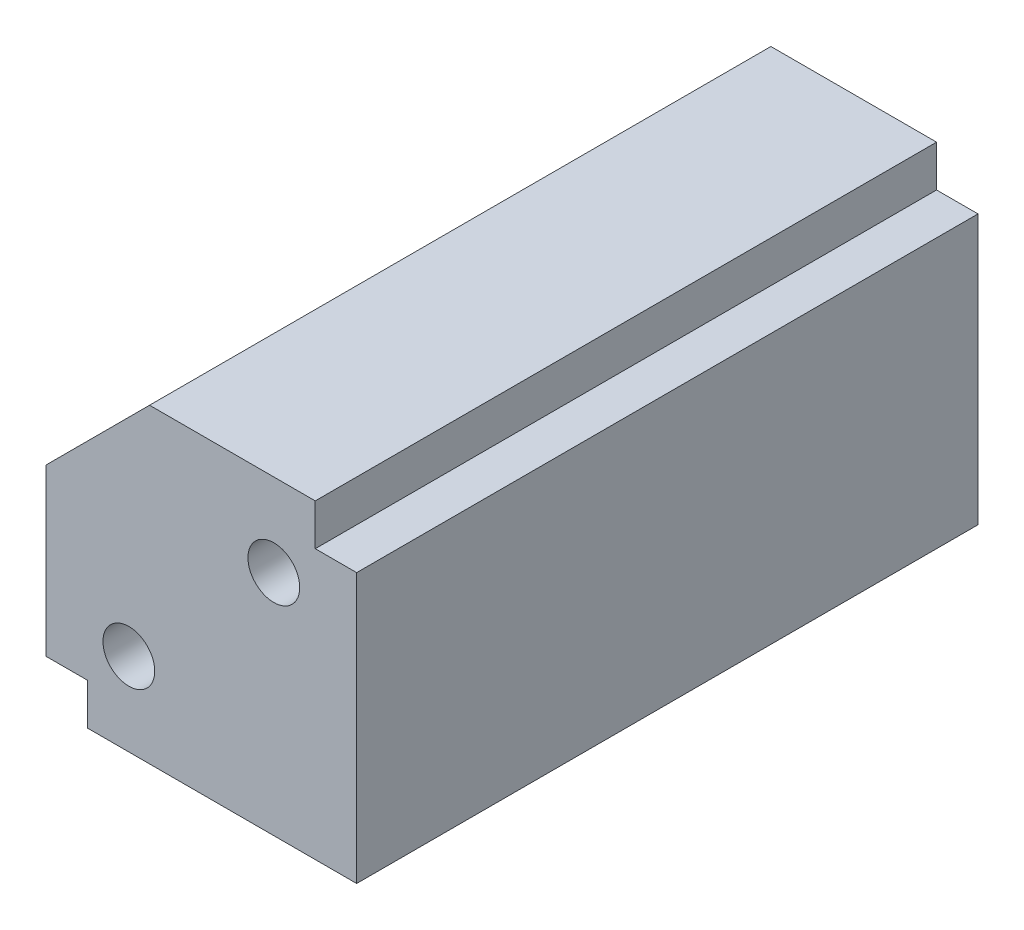
from build123d import *

# Parameters (mm, degrees)
SKETCH_1_W                  = 15
SKETCH_1_H                  = 15
EXTRUDE_1_DEPTH             = 30
CHAMFER_1_SIZE              = 5
HOLE_WIZARD_M3_2_AT_2_COUNT = 2
HOLE_WIZARD_M3_2_AT_2_PITCH = 9.899494937
SKETCH_5_W                  = 2
SKETCH_5_H                  = 30
CUT_EXTRUDE_1_DEPTH         = 2
SKETCH_6_W                  = 30
SKETCH_6_H                  = 2
CUT_EXTRUDE_2_DEPTH         = 2


with BuildPart() as part:
    # 草图1 → 凸台-拉伸1 (new body)
    with BuildSketch(Plane.XY):
        Rectangle(SKETCH_1_W, SKETCH_1_H)
    extrude(amount=EXTRUDE_1_DEPTH)

    # 倒角1
    chamfer_1_edges = [part.edges().sort_by_distance(p)[0] for p in [
        (-7.5, 7.5, 15),
    ]]
    chamfer(chamfer_1_edges, length=CHAMFER_1_SIZE)

    # 草图3 → M3 螺纹孔2 (revolve, cut)
    with BuildSketch(Plane(origin=(-3.5, -3.5, 30), x_dir=(0, -1, 0), z_dir=(1, 0, 0))):
        Polygon((0, 0), (0, 8.251075774), (1.25, 7.5), (1.25, 0), align=None)
    hole_wizard_m3_2 = revolve(axis=Axis((-3.5, -3.5, 36.35), (0, 0, -1)), mode=Mode.SUBTRACT)

    # M3 螺纹孔2 at 2: M3 螺纹孔2 ×2
    with Locations(*[Vector(0.707106781, 0.707106781, 0) * (i * HOLE_WIZARD_M3_2_AT_2_PITCH) for i in range(1, HOLE_WIZARD_M3_2_AT_2_COUNT)]):
        add(hole_wizard_m3_2, mode=Mode.SUBTRACT)

    # 镜向1: M3 螺纹孔2 across plane
    add(hole_wizard_m3_2.mirror(Plane(origin=(0, 0, 15), x_dir=(1, 0, 0), z_dir=(0, 0, -1))), mode=Mode.SUBTRACT)

    # 镜向1 copy 1 sketch → 镜向1 copy 1 (revolve, cut)
    with BuildSketch(Plane(origin=(3.5, 3.5, 0), x_dir=(0, -1, 0), z_dir=(1, 0, 0))):
        Polygon((0, 0), (0, -8.251075774), (1.25, -7.5), (1.25, 0), align=None)
    revolve(axis=Axis((3.5, 3.5, -6.35), (0, 0, -1)), mode=Mode.SUBTRACT)

    # 草图5 → 切除-拉伸1 (cut)
    with BuildSketch(Plane(origin=(0, 7.5, 0), x_dir=(1, 0, 0), z_dir=(0, 1, 0))):
        with Locations((6.5, -15)):
            Rectangle(SKETCH_5_W, SKETCH_5_H)
    extrude(amount=-CUT_EXTRUDE_1_DEPTH, mode=Mode.SUBTRACT)

    # 草图6 → 切除-拉伸2 (cut)
    with BuildSketch(Plane.ZY.offset(7.5)):
        with Locations((15, -6.5)):
            Rectangle(SKETCH_6_W, SKETCH_6_H)
    extrude(amount=-CUT_EXTRUDE_2_DEPTH, mode=Mode.SUBTRACT)


solid = part.part
